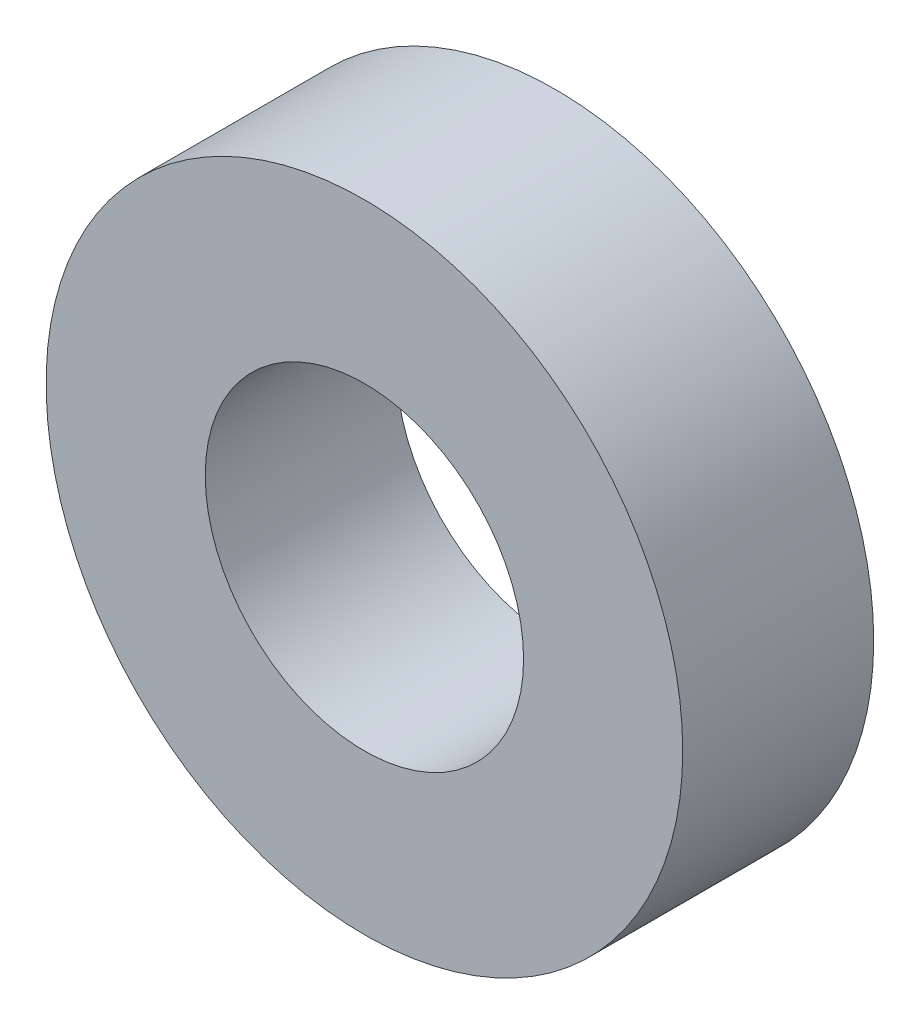
from build123d import *

# Parameters (mm, degrees)
SKETCH1_R                 = 5
BOSS_EXTRUDE1_DEPTH       = 3
F_5_0MM_DOWEL_HOLE1_D     = 5
F_5_0MM_DOWEL_HOLE1_DEPTH = 3


with BuildPart() as part:
    # Sketch1 → Boss-Extrude1 (new body)
    with BuildSketch(Plane.XY):
        Circle(SKETCH1_R)
    extrude(amount=BOSS_EXTRUDE1_DEPTH)

    # Ø5.0mm Dowel Hole1
    with Locations(Plane.XY.offset(3)):
        with Locations((0, 0)):
            Hole(F_5_0MM_DOWEL_HOLE1_D / 2, depth=F_5_0MM_DOWEL_HOLE1_DEPTH)


solid = part.part
